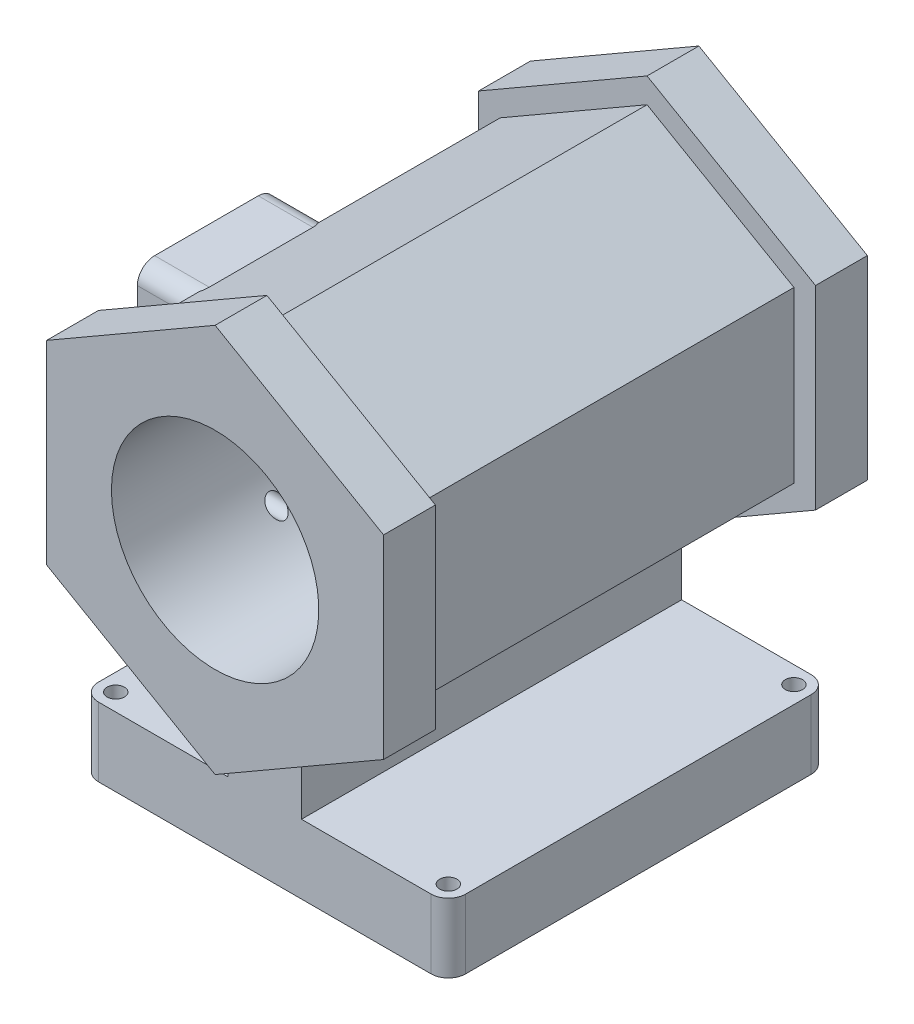
from build123d import *

# Parameters (mm, degrees)
BOSS_EXTRUDE1_DEPTH      = 5588
BOSS_EXTRUDE2_DEPTH      = 762
BOSS_EXTRUDE3_DEPTH      = 762
SKETCH5_W                = 2032
SKETCH5_H                = 2540
BOSS_EXTRUDE4_DEPTH      = 762
BOSS_EXTRUDE4_DEPTH_BACK = 762
FILLET8_R                = 254
SKETCH6_R                = 762
CUT_EXTRUDE1_DEPTH       = 3035.554
SKETCH7_R                = 1524
CUT_EXTRUDE2_DEPTH       = 7113
SKETCH10_R               = 127
CUT_EXTRUDE3_DEPTH       = 2538.476
SKETCH11_R               = 127
CUT_EXTRUDE4_DEPTH       = 1783.588


with BuildPart() as part:
    # Sketch1 → Boss-Extrude1 (new body)
    with BuildSketch(Plane.XY):
        Polygon((2667, -4572), (2667, -3556), (508, -3556), (508, -2199.704525612), (2159, -1246.49923118), (2159, 1246.49923118), (0, 2492.998462361), (-2159, 1246.49923118), (-2159, -1246.49923118), (-571.750359316, -2162.8982385), (-571.750359316, -3556), (-2730.750359316, -3556), (-2730.750359316, -4572), (0, -4572), align=None)
    extrude(amount=BOSS_EXTRUDE1_DEPTH)

    # Sketch3 → Boss-Extrude2 (add)
    with BuildSketch(Plane.XY.offset(5588)):
        Polygon((0, 2859.615883296), (-2476.5, 1429.807941648), (-2476.5, -1429.807941648), (0, -2859.615883296), (2476.5, -1429.807941648), (2476.5, 1429.807941648), align=None)
    extrude(amount=BOSS_EXTRUDE2_DEPTH)

    # Sketch4 → Boss-Extrude3 (add)
    with BuildSketch(Plane(origin=(0, 0, 0), x_dir=(-1, 0, 0), z_dir=(0, 0, -1))):
        Polygon((0, 2859.615883296), (-2476.5, 1429.807941648), (-2476.5, -1429.807941648), (0, -2859.615883296), (2476.5, -1429.807941648), (2476.5, 1429.807941648), align=None)
    extrude(amount=BOSS_EXTRUDE3_DEPTH)

    # Sketch5 → Boss-Extrude4 (add, two sides)
    with BuildSketch(Plane.ZY.offset(2159)) as boss_extrude4_sk:
        with Locations((3556, 0)):
            Rectangle(SKETCH5_W, SKETCH5_H)
    extrude(amount=BOSS_EXTRUDE4_DEPTH)
    extrude(boss_extrude4_sk.sketch, amount=-BOSS_EXTRUDE4_DEPTH_BACK)

    # Fillet8
    fillet8_edges = [part.edges().sort_by_distance(p)[0] for p in [
        (2667, -4064, 5588),
        (2667, -4064, 0),
        (-2730.750359316, -4064, 0),
        (-2730.750359316, -4064, 5588),
        (-2519.647737194, 1270, 4572),
        (-2519.647737194, 1270, 2540),
        (-2519.647737194, -1270, 4572),
        (-2519.647737194, -1270, 2540),
    ]]
    fillet(fillet8_edges, radius=FILLET8_R)

    # Sketch6 → Cut-Extrude1 (cut)
    with BuildSketch(Plane.ZY.offset(2921)):
        with Locations((3556, 0)):
            Circle(SKETCH6_R)
    extrude(amount=-CUT_EXTRUDE1_DEPTH, mode=Mode.SUBTRACT)

    # Sketch7 → Cut-Extrude2 (cut, through all)
    with BuildSketch(Plane(origin=(0, 0, -762), x_dir=(-1, 0, 0), z_dir=(0, 0, -1))):
        Circle(SKETCH7_R)
    extrude(amount=-CUT_EXTRUDE2_DEPTH, mode=Mode.SUBTRACT)

    # Sketch10 → Cut-Extrude3 (cut)
    with BuildSketch(Plane.ZY.offset(2921)):
        with Locations((4318, -1016)):
            Circle(SKETCH10_R)
        with Locations((4318, 1016)):
            Circle(SKETCH10_R)
        with Locations((2794, 1016)):
            Circle(SKETCH10_R)
        with Locations((2794, -1016)):
            Circle(SKETCH10_R)
    extrude(amount=-CUT_EXTRUDE3_DEPTH, mode=Mode.SUBTRACT)

    # Sketch11 → Cut-Extrude4 (cut)
    with BuildSketch(Plane.XZ.offset(4572)):
        with Locations((-2476.750359316, 254)):
            Circle(SKETCH11_R)
        with Locations((2413, 254)):
            Circle(SKETCH11_R)
        with Locations((2413, 5334)):
            Circle(SKETCH11_R)
        with Locations((-2476.750359316, 5334)):
            Circle(SKETCH11_R)
    extrude(amount=-CUT_EXTRUDE4_DEPTH, mode=Mode.SUBTRACT)


solid = part.part
